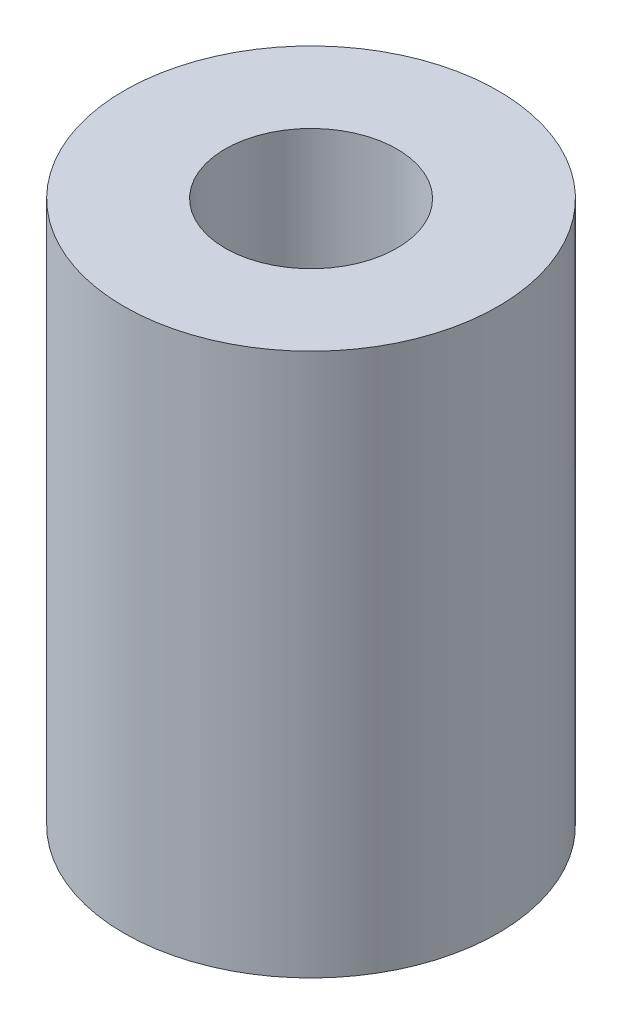
from build123d import *

# Parameters (mm, degrees)
SKETCH1_R           = 3.1
BOSS_EXTRUDE1_DEPTH = 9
SKETCH2_R           = 1.425
CUT_EXTRUDE1_DEPTH  = 10


with BuildPart() as part:
    # Sketch1 → Boss-Extrude1 (new body)
    with BuildSketch(Plane(origin=(0, 0, 0), x_dir=(1, 0, 0), z_dir=(0, 1, 0))):
        Circle(SKETCH1_R)
    extrude(amount=BOSS_EXTRUDE1_DEPTH)

    # Sketch2 → Cut-Extrude1 (cut, through all)
    with BuildSketch(Plane(origin=(0, 9, 0), x_dir=(1, 0, 0), z_dir=(0, 1, 0))):
        Circle(SKETCH2_R)
    extrude(amount=-CUT_EXTRUDE1_DEPTH, mode=Mode.SUBTRACT)


solid = part.part
